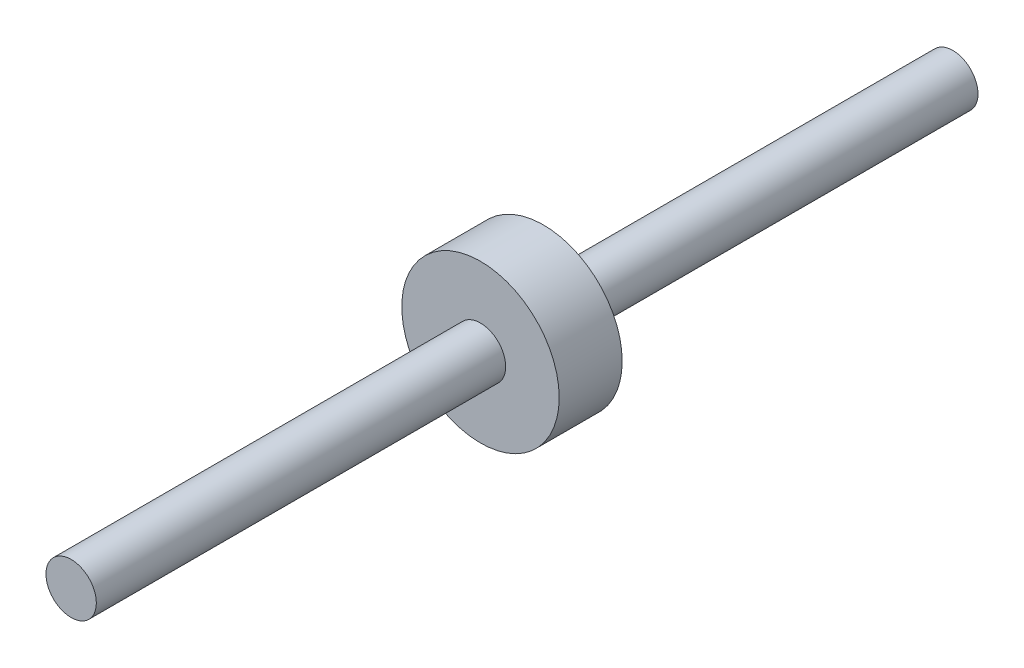
from build123d import *


with BuildPart() as part:
    # Szkic1 → Obrót1 (revolve)
    with BuildSketch(Plane(origin=(0, 0, 0), x_dir=(1, 0, 0), z_dir=(0, 1, 0))):
        Polygon((-12.5, 75), (-12.5, 65), (-4, 65), (-4, 0), (0, 0), (0, 140), (-4, 140), (-4, 75), align=None)
    revolve(axis=Axis((0, 0, 0), (0, 0, -1)))


solid = part.part
